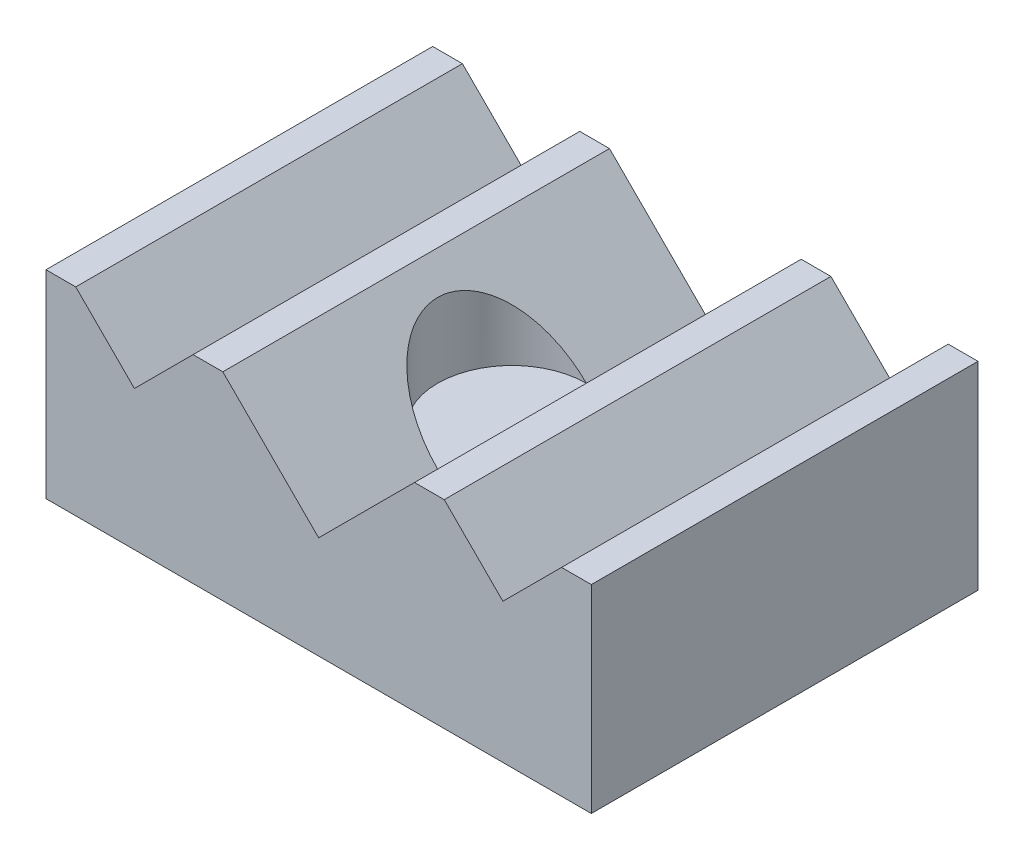
from build123d import *

# Parameters (mm, degrees)
SKETCH1_W           = 20.955
SKETCH1_H           = 14.859
BOSS_EXTRUDE1_DEPTH = 7.62
CUT_EXTRUDE1_DEPTH  = 15.859
SKETCH3_R           = 2.8575
CUT_EXTRUDE2_DEPTH  = 4.683
SKETCH4_R           = 0.9271
CUT_EXTRUDE3_DEPTH  = 3.81


with BuildPart() as part:
    # Sketch1 → Boss-Extrude1 (new body)
    with BuildSketch(Plane(origin=(0, 0, 0), x_dir=(1, 0, 0), z_dir=(0, 1, 0))):
        with Locations((10.4775, 7.4295)):
            Rectangle(SKETCH1_W, SKETCH1_H)
    extrude(amount=BOSS_EXTRUDE1_DEPTH)

    # Sketch2 → Cut-Extrude1 (cut, through all)
    with BuildSketch(Plane.XY):
        Polygon((5.6515, 7.62), (1.143, 7.62), (3.39725, 5.36575), align=None)
        Polygon((14.1605, 7.62), (6.7945, 7.62), (10.4775, 3.937), align=None)
        Polygon((19.812, 7.62), (15.3035, 7.62), (17.55775, 5.36575), align=None)
    extrude(amount=-CUT_EXTRUDE1_DEPTH, mode=Mode.SUBTRACT)

    # Sketch3 → Cut-Extrude2 (cut, through all)
    with BuildSketch(Plane(origin=(0, 3.937, 0), x_dir=(1, 0, 0), z_dir=(0, 1, 0))):
        with Locations((10.4775, 7.4295)):
            Circle(SKETCH3_R)
    extrude(amount=CUT_EXTRUDE2_DEPTH, mode=Mode.SUBTRACT)

    # Sketch4 → Cut-Extrude3 (cut)
    with BuildSketch(Plane.XZ):
        with Locations((4.0386, -3.7846)):
            Circle(SKETCH4_R)
        with Locations((4.0386, -11.0744)):
            Circle(SKETCH4_R)
        with Locations((10.4775, -7.4295)):
            Circle(SKETCH4_R)
        with Locations((16.9164, -11.0744)):
            Circle(SKETCH4_R)
        with Locations((16.9164, -3.7846)):
            Circle(SKETCH4_R)
    extrude(amount=-CUT_EXTRUDE3_DEPTH, mode=Mode.SUBTRACT)


solid = part.part
